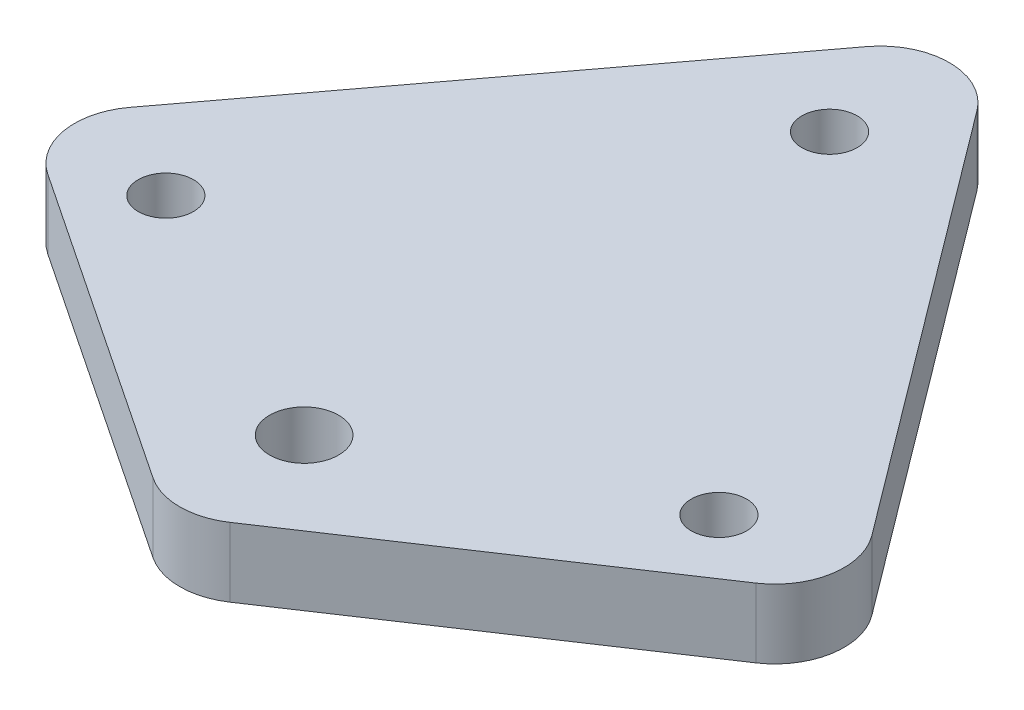
from build123d import *

# Parameters (mm, degrees)
SKETCH2_R           = 3.175
SKETCH2_R_2         = 2.54
BOSS_EXTRUDE2_DEPTH = 6.35
FILLET3_R           = 6.35


with BuildPart() as part:
    # Sketch2 → Boss-Extrude2 (new body)
    with BuildSketch(Plane(origin=(0, 0, 0), x_dir=(1, 0, 0), z_dir=(0, 1, 0))):
        Polygon((0, 63.5), (-38.1, 12.7), (0, -12.7), (38.1, 12.7), align=None)
        Circle(SKETCH2_R, mode=Mode.SUBTRACT)
        with Locations((-25.4, 12.7)):
            Circle(SKETCH2_R_2, mode=Mode.SUBTRACT)
        with Locations((0, 48.26)):
            Circle(SKETCH2_R_2, mode=Mode.SUBTRACT)
        with Locations((25.4, 12.7)):
            Circle(SKETCH2_R_2, mode=Mode.SUBTRACT)
    extrude(amount=BOSS_EXTRUDE2_DEPTH)

    # Fillet3
    fillet3_edges = [part.edges().sort_by_distance(p)[0] for p in [
        (0, 3.175, 12.7),
        (-38.1, 3.175, -12.7),
        (0, 3.175, -63.5),
        (38.1, 3.175, -12.7),
    ]]
    fillet(fillet3_edges, radius=FILLET3_R)


solid = part.part
